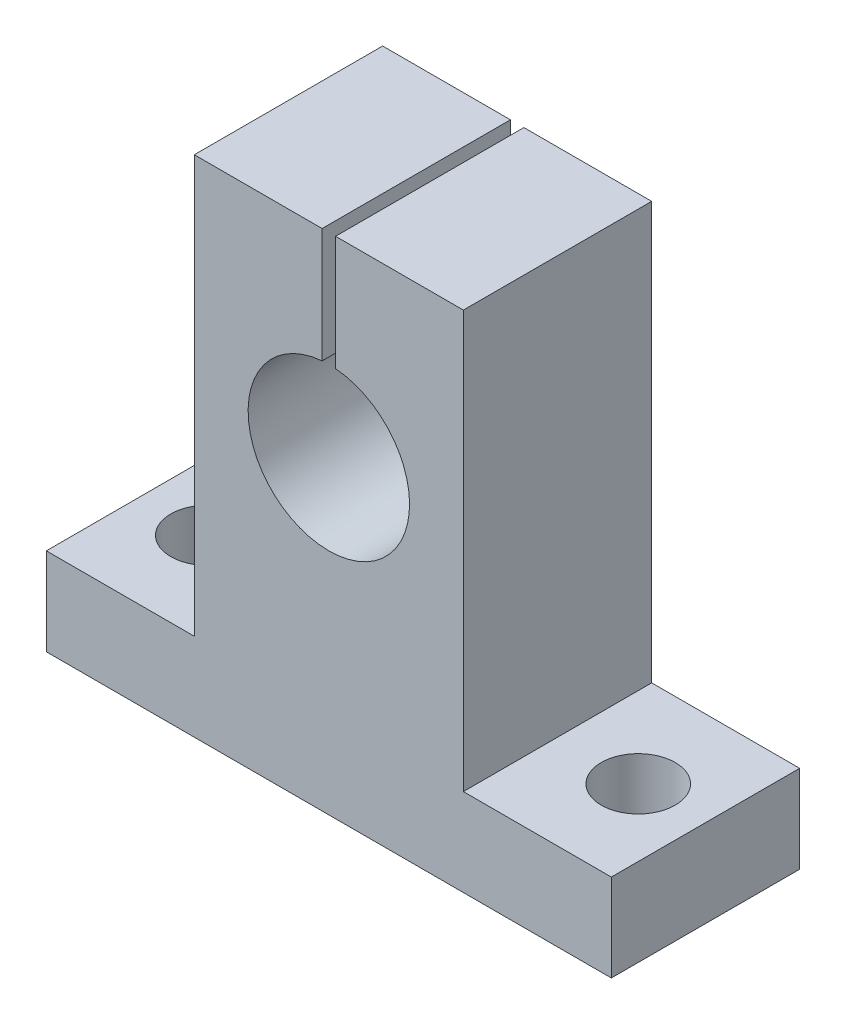
from build123d import *

# Parameters (mm, degrees)
Y_KSEKLIK_EKSTR_ZYON2_DEPTH       = 14
KES_EKSTR_ZYON1_REACH             = 39.5
IZIM2_R                           = 2.75
KES_EKSTR_ZYON1_DIRECTION_2_DEPTH = 1


with BuildPart() as part:
    # Çizim1 → Yükseklik-Ekstrüzyon2 (new body)
    with BuildSketch(Plane.XY):
        with BuildLine():
            Line((21, -23), (-21, -23))
            Line((-21, -23), (-21, -16.5))
            Line((-21, -16.5), (-10, -16.5))
            Line((-10, -16.5), (-10, 14.5))
            Line((-10, 14.5), (-0.5, 14.5))
            Line((-0.5, 14.5), (-0.5, 5.979130372))
            ThreePointArc((-0.5, 5.979130372), (0, -6), (0.5, 5.979130372))
            Line((0.5, 5.979130372), (0.5, 14.5))
            Line((0.5, 14.5), (10, 14.5))
            Line((10, 14.5), (10, -16.5))
            Line((10, -16.5), (21, -16.5))
            Line((21, -16.5), (21, -23))
        make_face()
    extrude(amount=Y_KSEKLIK_EKSTR_ZYON2_DEPTH)

    # Çizim2 → Kes-Ekstrüzyon1 (cut, up to next)
    with BuildSketch(Plane.XZ.offset(23), mode=Mode.PRIVATE) as kes_ekstr_zyon1_sk1:
        with Locations((-16, 7)):
            Circle(IZIM2_R)
    kes_ekstr_zyon1_tool1 = extrude(kes_ekstr_zyon1_sk1.sketch, amount=-KES_EKSTR_ZYON1_REACH, mode=Mode.PRIVATE) & part.part
    add(kes_ekstr_zyon1_tool1.solids().sort_by_distance((-16, -23, 7))[0], mode=Mode.SUBTRACT)
    # Çizim2 → Kes-Ekstrüzyon1 (cut, up to next)
    with BuildSketch(Plane.XZ.offset(23), mode=Mode.PRIVATE) as kes_ekstr_zyon1_sk2:
        with Locations((16, 7)):
            Circle(IZIM2_R)
    kes_ekstr_zyon1_tool2 = extrude(kes_ekstr_zyon1_sk2.sketch, amount=-KES_EKSTR_ZYON1_REACH, mode=Mode.PRIVATE) & part.part
    add(kes_ekstr_zyon1_tool2.solids().sort_by_distance((16, -23, 7))[0], mode=Mode.SUBTRACT)

    # Çizim2 → Kes-Ekstrüzyon1 direction 2 (cut)
    with BuildSketch(Plane.XZ.offset(23)):
        with Locations((-16, 7)):
            Circle(IZIM2_R)
        with Locations((16, 7)):
            Circle(IZIM2_R)
    extrude(amount=KES_EKSTR_ZYON1_DIRECTION_2_DEPTH, mode=Mode.SUBTRACT)


solid = part.part
